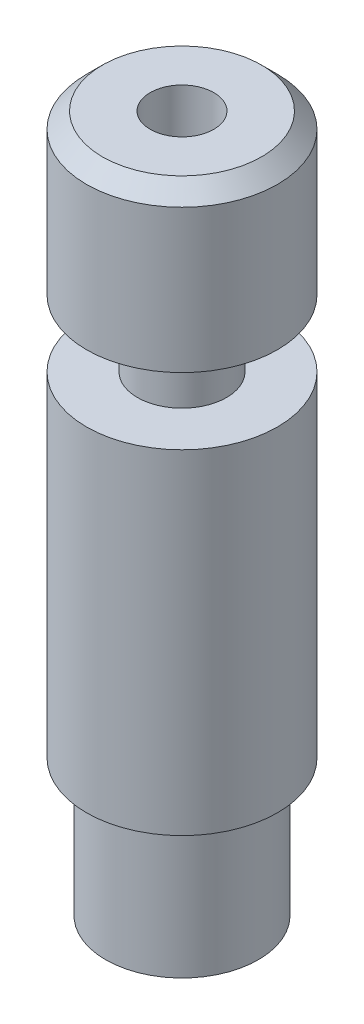
from build123d import *


with BuildPart() as part:
    # Sketch1 → Revolve1 (revolve)
    with BuildSketch(Plane.XY):
        Polygon((1, -10.694337567), (1, 11.094337567), (2.5, 11.094337567), (3, 10.594337567), (3, 6.094337567), (1.4, 6.094337567), (1.4, 3.994337567), (3, 3.994337567), (3, -6.505662433), (2.4, -6.505662433), (2.4, -10.805662433), (1.9, -11.094337567), (1.4, -11.094337567), align=None)
    revolve(axis=Axis((0, 11.094337567, 0), (0, -1, 0)))


solid = part.part
